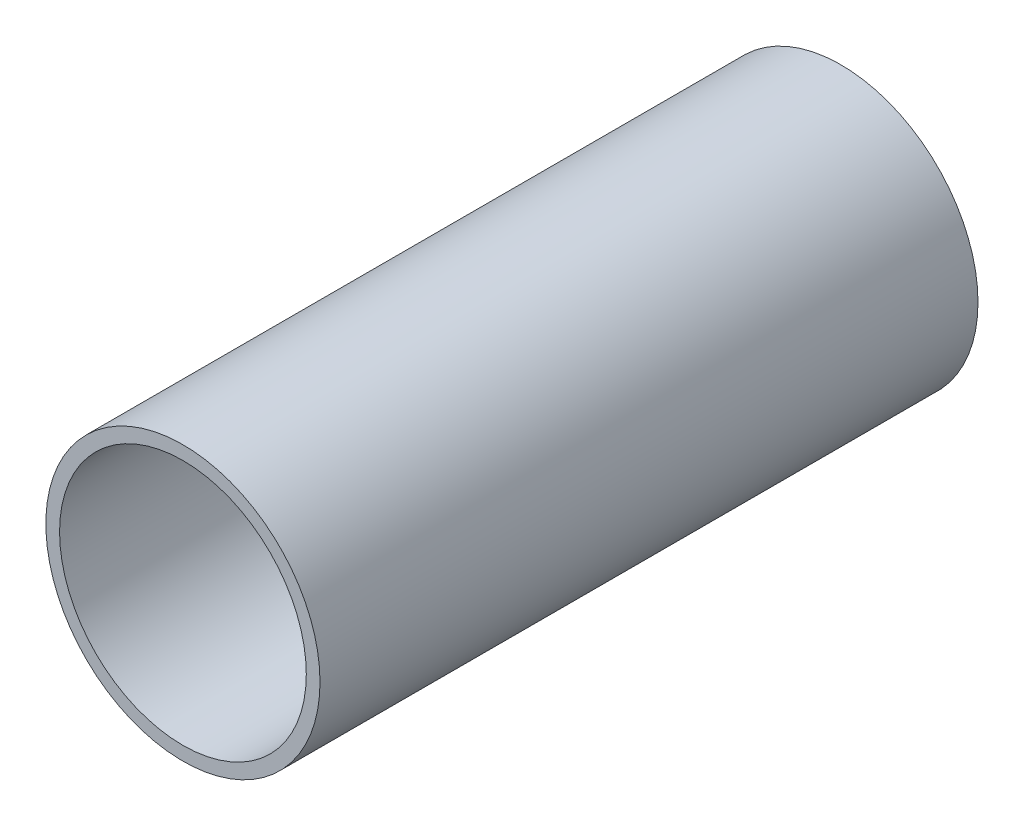
from build123d import *

# Parameters (mm, degrees)
SKETCH5_R           = 31.75
SKETCH5_R_2         = 28.575
BOSS_EXTRUDE1_DEPTH = 152.4


with BuildPart() as part:
    # Sketch5 → Boss-Extrude1 (new body)
    with BuildSketch(Plane.XY):
        Circle(SKETCH5_R)
        Circle(SKETCH5_R_2, mode=Mode.SUBTRACT)
    extrude(amount=BOSS_EXTRUDE1_DEPTH)


solid = part.part
